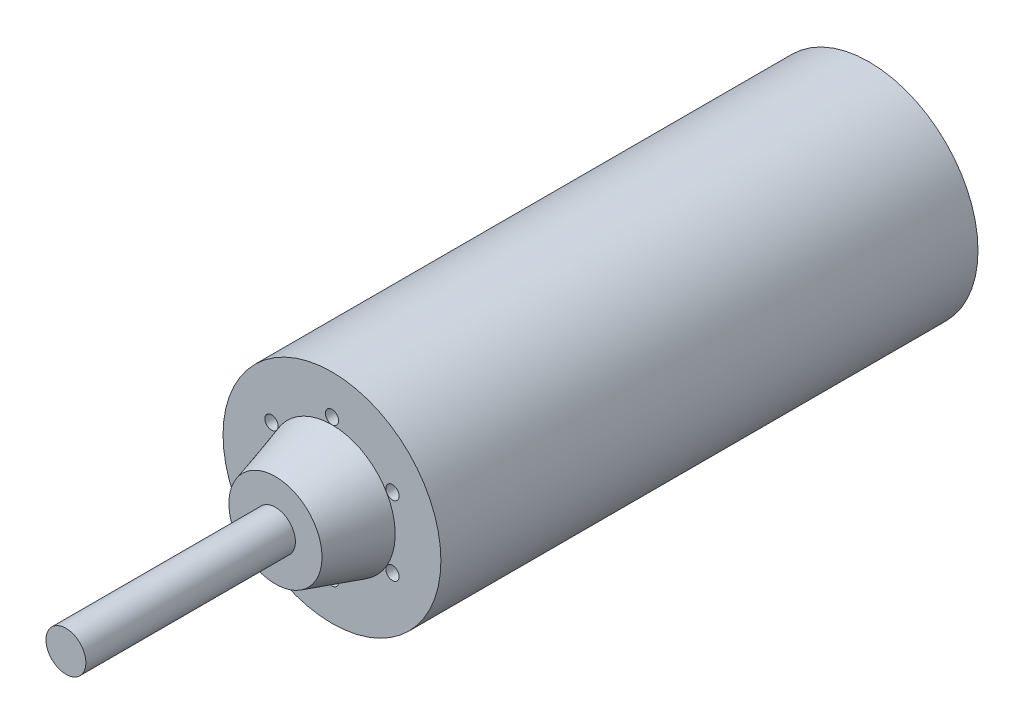
from build123d import *

# Parameters (mm, degrees)
SKETCH1_R           = 32.75
BOSS_EXTRUDE1_DEPTH = 80.75
SKETCH12_R          = 6
BOSS_EXTRUDE5_DEPTH = 63
SKETCH13_R          = 2
CUT_EXTRUDE1_DEPTH  = 10
CIRPATTERN1_COUNT   = 6
SKETCH14_R          = 2.5
CUT_EXTRUDE2_DEPTH  = 10
CIRPATTERN2_COUNT   = 4


with BuildPart() as part:
    # Sketch1 → Boss-Extrude1 (new body, symmetric)
    with BuildSketch(Plane.XY):
        Circle(SKETCH1_R)
    extrude(amount=BOSS_EXTRUDE1_DEPTH, both=True)

    # Sketch10 → Revolve1 (revolve)
    with BuildSketch(Plane(origin=(0, 0, 0), x_dir=(0, 0, -1), z_dir=(1, 0, 0))):
        Polygon((-97.75, 0), (-97.75, 14), (-80.75, 19), (-80.75, 0), align=None)
    revolve(axis=Axis((0, 0, 1000), (0, 0, -1)))

    # Sketch12 → Boss-Extrude5 (add)
    with BuildSketch(Plane.XY.offset(97.75)):
        Circle(SKETCH12_R)
    extrude(amount=BOSS_EXTRUDE5_DEPTH)

    # Sketch13 → Cut-Extrude1 (cut)
    with BuildSketch(Plane.XY.offset(80.75)):
        with Locations((0, 21)):
            Circle(SKETCH13_R)
    cut_extrude1 = extrude(amount=-CUT_EXTRUDE1_DEPTH, mode=Mode.SUBTRACT)

    # CirPattern1: Cut-Extrude1 ×6 about axis
    cirpattern1_axis = Axis((0, 0, 0), (0, 0, 1))
    for i in range(1, CIRPATTERN1_COUNT):
        add(cut_extrude1.rotate(cirpattern1_axis, i * 360 / CIRPATTERN1_COUNT), mode=Mode.SUBTRACT)

    # Sketch14 → Cut-Extrude2 (cut)
    with BuildSketch(Plane(origin=(0, 0, -80.75), x_dir=(-1, 0, 0), z_dir=(0, 0, -1))):
        with Locations((14.849242405, 14.849242405)):
            Circle(SKETCH14_R)
    cut_extrude2 = extrude(amount=-CUT_EXTRUDE2_DEPTH, mode=Mode.SUBTRACT)

    # CirPattern2: Cut-Extrude2 ×4 about axis
    cirpattern2_axis = Axis((0, 0, 0), (0, 0, 1))
    for i in range(1, CIRPATTERN2_COUNT):
        add(cut_extrude2.rotate(cirpattern2_axis, i * 360 / CIRPATTERN2_COUNT), mode=Mode.SUBTRACT)


solid = part.part
